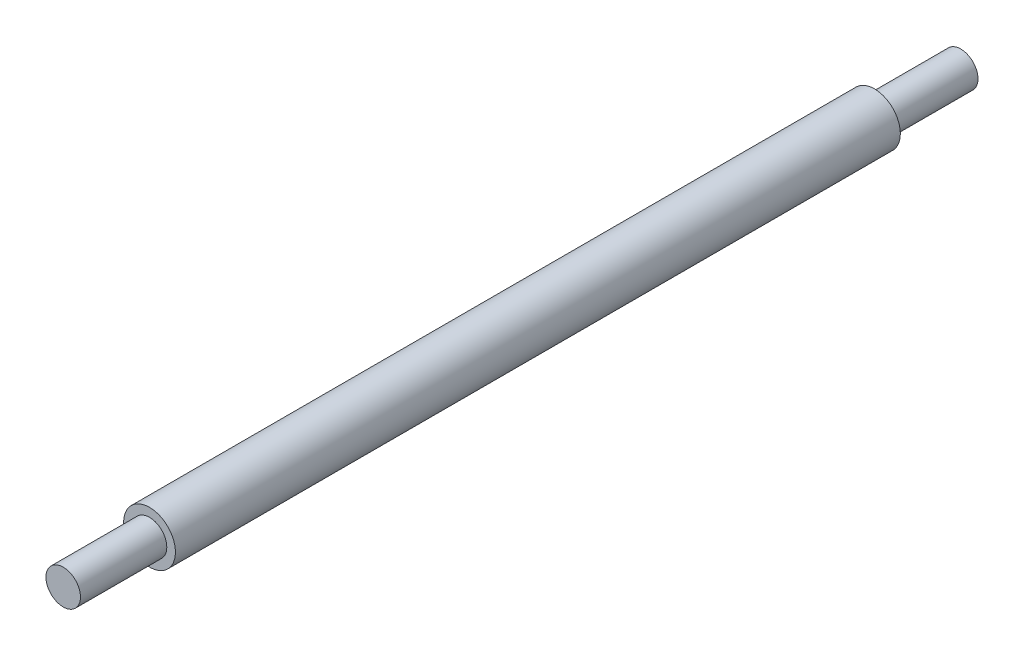
from build123d import *

# Parameters (mm, degrees)
SKETCH1_R           = 3
BOSS_EXTRUDE1_DEPTH = 42
SKETCH1_3_R         = 2
BOSS_EXTRUDE2_DEPTH = 52


with BuildPart() as part:
    # Sketch1 → Boss-Extrude1 (new, symmetric)
    with BuildSketch(Plane.XY):
        Circle(SKETCH1_R)
    extrude(amount=BOSS_EXTRUDE1_DEPTH, both=True)

    # Sketch1_3 → Boss-Extrude2 (add, symmetric)
    with BuildSketch(Plane.XY):
        Circle(SKETCH1_3_R)
    extrude(amount=BOSS_EXTRUDE2_DEPTH, both=True)


solid = part.part
